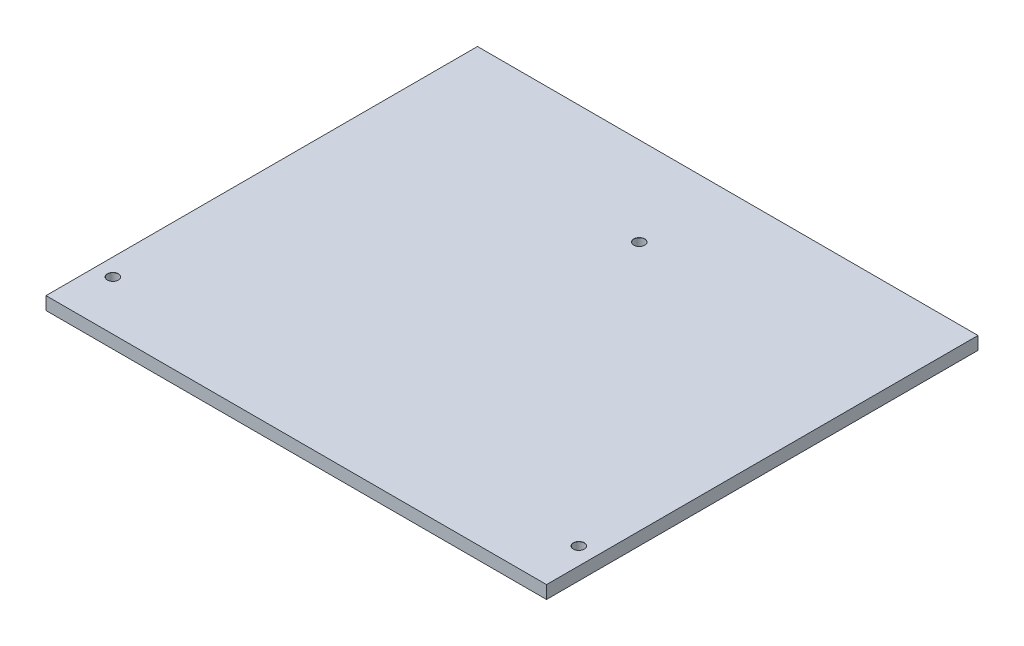
from build123d import *

# Parameters (mm, degrees)
SKETCH1_W                         = 116
SKETCH1_H                         = 100
BOSS_EXTRUDE1_DEPTH               = 3
TAP_DRILL_FOR_M3_TAP1_D           = 2.5
TAP_DRILL_FOR_M3_TAP1_CSINK_D     = 2.55
TAP_DRILL_FOR_M3_TAP1_CSINK_ANGLE = 90


with BuildPart() as part:
    # Sketch1 → Boss-Extrude1 (new body)
    with BuildSketch(Plane(origin=(0, 0, 0), x_dir=(1, 0, 0), z_dir=(0, 1, 0))):
        Rectangle(SKETCH1_W, SKETCH1_H)
    extrude(amount=BOSS_EXTRUDE1_DEPTH)

    # Tap Drill for M3 Tap1 (through all)
    with Locations(Plane(origin=(0, 3, 0), x_dir=(1, 0, 0), z_dir=(0, 1, 0))):
        with Locations((0, 29.5), (-54, -38.5), (54, -38.5)):
            CounterSinkHole(TAP_DRILL_FOR_M3_TAP1_D / 2, TAP_DRILL_FOR_M3_TAP1_CSINK_D / 2, counter_sink_angle=TAP_DRILL_FOR_M3_TAP1_CSINK_ANGLE)


solid = part.part
